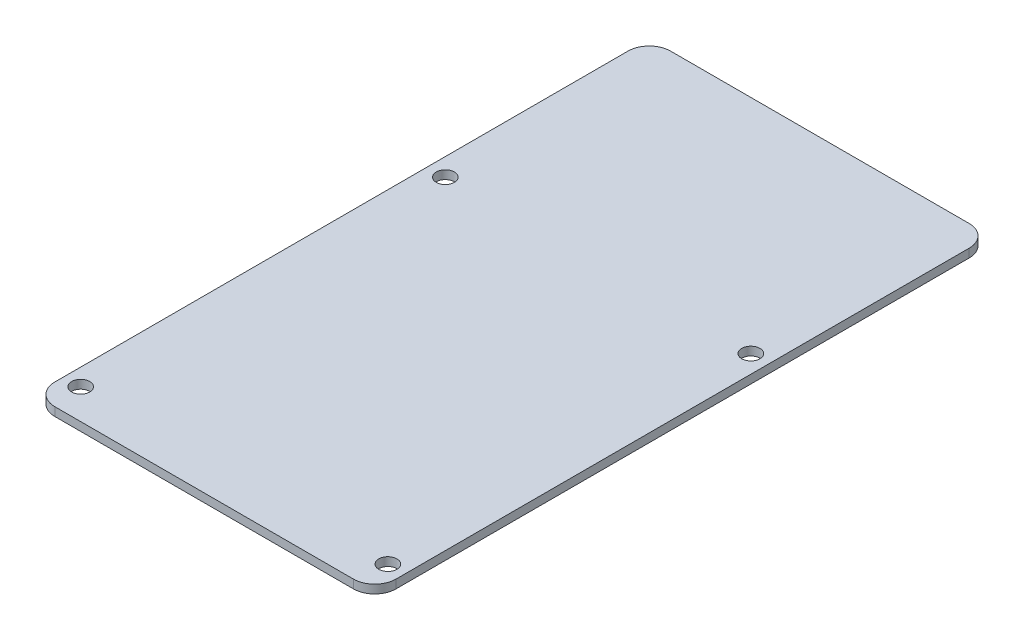
from build123d import *

# Parameters (mm, degrees)
SKETCH1_R           = 2.125
BOSS_EXTRUDE1_DEPTH = 2


with BuildPart() as part:
    # Sketch1 → Boss-Extrude1 (new body)
    with BuildSketch(Plane(origin=(0, 0, 0), x_dir=(-1, 0, 0), z_dir=(0, 1, 0))):
        with BuildLine():
            Line((44.041758229, -68.058283539), (44.041758229, 66.305377739))
            ThreePointArc((44.041758229, 66.305377739), (42.577292135, 69.840911645), (39.041758229, 71.305377739))
            Line((39.041758229, 71.305377739), (-30.958241771, 71.305377739))
            ThreePointArc((-30.958241771, 71.305377739), (-34.493775676, 69.840911645), (-35.958241771, 66.305377739))
            Line((-35.958241771, 66.305377739), (-35.958241771, -68.058283539))
            ThreePointArc((-35.958241771, -68.058283539), (-34.493775676, -71.593817445), (-30.958241771, -73.058283539))
            Line((-30.958241771, -73.058283539), (39.041758229, -73.058283539))
            ThreePointArc((39.041758229, -73.058283539), (42.577292135, -71.593817445), (44.041758229, -68.058283539))
        make_face()
        with Locations((-31.767919032, -21.058283539)):
            Circle(SKETCH1_R, mode=Mode.SUBTRACT)
        with Locations((39.851435491, -21.058283539)):
            Circle(SKETCH1_R, mode=Mode.SUBTRACT)
        with Locations((40.041758229, 64.22705795)):
            Circle(SKETCH1_R, mode=Mode.SUBTRACT)
        with Locations((-31.958241771, 64.22705795)):
            Circle(SKETCH1_R, mode=Mode.SUBTRACT)
    extrude(amount=BOSS_EXTRUDE1_DEPTH)


solid = part.part
